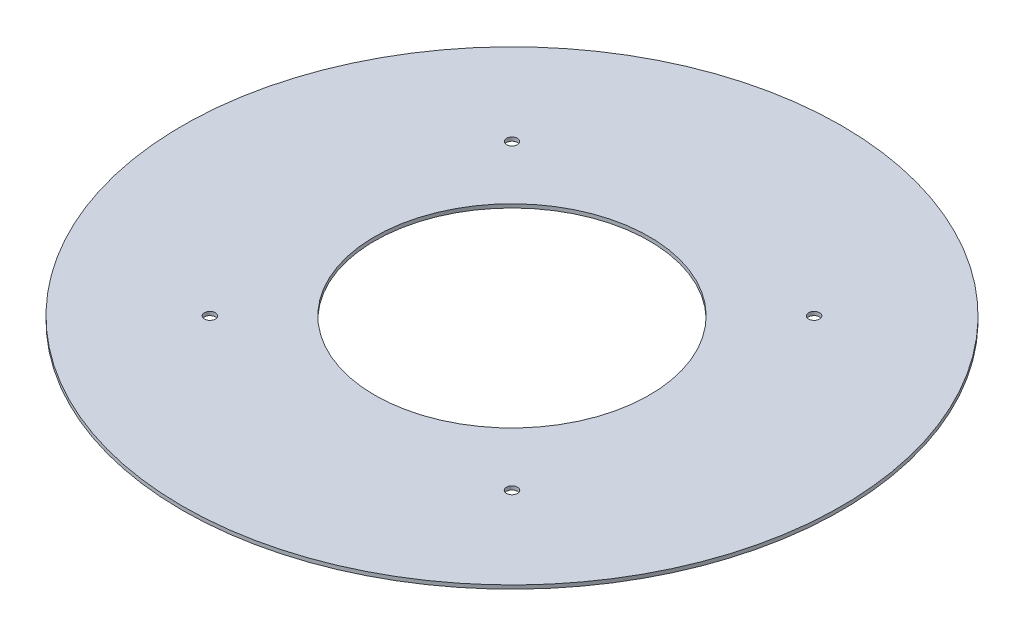
from build123d import *

# Parameters (mm, degrees)
SKETCH1_R           = 180
SKETCH1_R_2         = 75
SKETCH1_R_3         = 3
BOSS_EXTRUDE1_DEPTH = 2


with BuildPart() as part:
    # Sketch1 → Boss-Extrude1 (new body)
    with BuildSketch(Plane(origin=(0, 0, 0), x_dir=(1, 0, 0), z_dir=(0, 1, 0))):
        Circle(SKETCH1_R)
        Circle(SKETCH1_R_2, mode=Mode.SUBTRACT)
        with Locations((-82.5, 82.5)):
            Circle(SKETCH1_R_3, mode=Mode.SUBTRACT)
        with Locations((82.5, 82.5)):
            Circle(SKETCH1_R_3, mode=Mode.SUBTRACT)
        with Locations((82.5, -82.5)):
            Circle(SKETCH1_R_3, mode=Mode.SUBTRACT)
        with Locations((-82.5, -82.5)):
            Circle(SKETCH1_R_3, mode=Mode.SUBTRACT)
    extrude(amount=BOSS_EXTRUDE1_DEPTH)


solid = part.part
